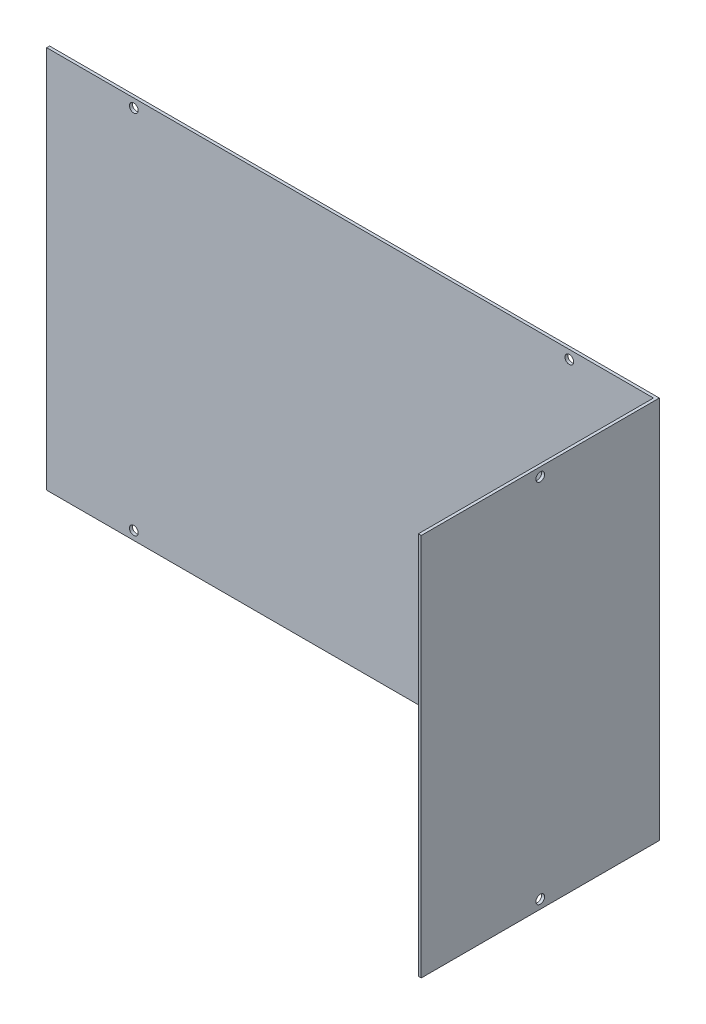
from build123d import *

# Parameters (mm, degrees)
SKETCH_1_W          = 210
SKETCH_1_H          = 132
EXTRUDE_1_DEPTH     = 1
SKETCH_3_W          = 1
SKETCH_3_H          = 132
EXTRUDE_2_DEPTH     = 81
SKETCH_2_R          = 1.5
CUT_EXTRUDE_1_DEPTH = 1
SKETCH_4_R          = 1.5
CUT_EXTRUDE_2_DEPTH = 211


with BuildPart() as part:
    # 草图1 → 凸台-拉伸1 (new body)
    with BuildSketch(Plane.XY):
        Rectangle(SKETCH_1_W, SKETCH_1_H)
    extrude(amount=EXTRUDE_1_DEPTH)

    # 草图3 → 凸台-拉伸2 (add)
    with BuildSketch(Plane.XY.offset(1)):
        with Locations((104.5, 0)):
            Rectangle(SKETCH_3_W, SKETCH_3_H)
    extrude(amount=EXTRUDE_2_DEPTH)

    # 草图2 → 切除-拉伸1 (cut)
    with BuildSketch(Plane.XY.offset(1)):
        with Locations((-75, 63)):
            Circle(SKETCH_2_R)
        with Locations((75, 63)):
            Circle(SKETCH_2_R)
        with Locations((75, -63)):
            Circle(SKETCH_2_R)
        with Locations((-75, -63)):
            Circle(SKETCH_2_R)
    extrude(amount=-CUT_EXTRUDE_1_DEPTH, mode=Mode.SUBTRACT)

    # 草图4 → 切除-拉伸2 (cut, through all)
    with BuildSketch(Plane(origin=(105, 0, 0), x_dir=(0, 0, -1), z_dir=(1, 0, 0))):
        with Locations((-41, 63)):
            Circle(SKETCH_4_R)
        with Locations((-41, -63)):
            Circle(SKETCH_4_R)
    extrude(amount=-CUT_EXTRUDE_2_DEPTH, mode=Mode.SUBTRACT)


solid = part.part
